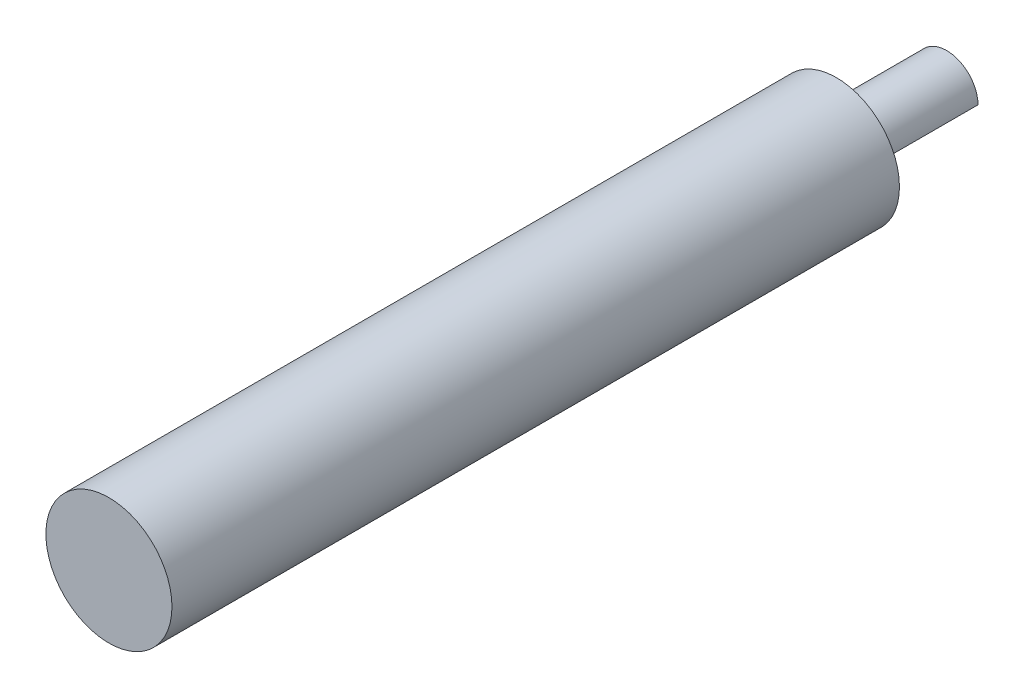
from build123d import *

# Parameters (mm, degrees)
SKETCH1_R               = 3.1623
BOSS_EXTRUDE1_DEPTH     = 11.0998
CUT_EXTRUDE1_DEPTH      = 1
CUT_EXTRUDE1_DEPTH_BACK = 12.0998
SKETCH3_R               = 6.35
BOSS_EXTRUDE2_DEPTH     = 73.279


with BuildPart() as part:
    # Sketch1 → Boss-Extrude1 (new body)
    with BuildSketch(Plane.XY):
        Circle(SKETCH1_R)
    extrude(amount=BOSS_EXTRUDE1_DEPTH)

    # Sketch2 → Cut-Extrude1 (cut, two sides)
    with BuildSketch(Plane(origin=(0, 0, 0), x_dir=(-1, 0, 0), z_dir=(0, 0, -1))) as cut_extrude1_sk:
        Polygon((17.073178183, -20.234228338), (0.001249598, -3.162299753), (-3.162299753, 0.001249598), (-20.234228338, 17.073178183), (-54.378085507, -17.070678986), (-17.070678986, -54.378085507), align=None)
    extrude(amount=CUT_EXTRUDE1_DEPTH, mode=Mode.SUBTRACT)
    extrude(cut_extrude1_sk.sketch, amount=-CUT_EXTRUDE1_DEPTH_BACK, mode=Mode.SUBTRACT)

    # Sketch3 → Boss-Extrude2 (add)
    with BuildSketch(Plane.XY.offset(11.0998)):
        Circle(SKETCH3_R)
    extrude(amount=BOSS_EXTRUDE2_DEPTH)


solid = part.part
